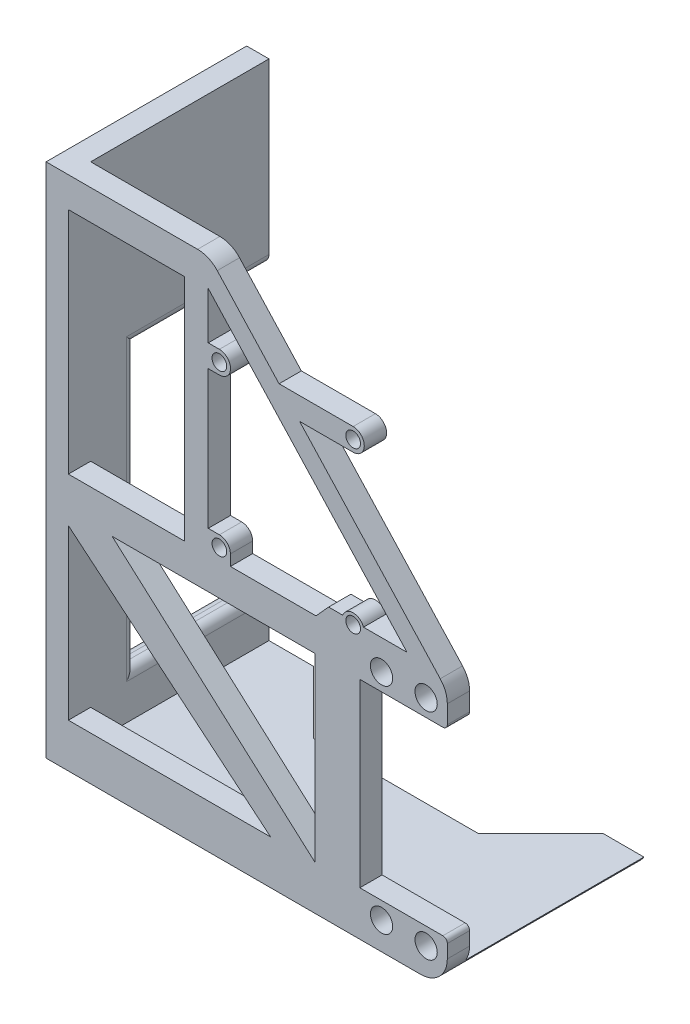
from build123d import *

# Parameters (mm, degrees)
SKETCH_2_R          = 2.5
SKETCH_2_R_2        = 1.65
EXTRUDE_1_DEPTH     = 5
SKETCH_3_W          = 5
SKETCH_3_H          = 7.033503338
EXTRUDE_2_DEPTH     = 40
CUT_EXTRUDE_1_REACH = 7
SKETCH_6_W          = 30
SKETCH_6_H          = 63
CUT_EXTRUDE_2_DEPTH = 10
FILLET_1_R          = 6
FILLET_2_R          = 2
FILLET_3_R          = 1


with BuildPart() as part:
    # 草图2 → 凸台-拉伸1 (new body)
    with BuildSketch(Plane.XY):
        with BuildLine():
            Line((90, -2.836370327), (90, -0.033503338))
            Line((90, -0.033503338), (90, 7.163629673))
            Line((90, 7.163629673), (70.37335416, 7.163629673))
            Line((70.37335416, 7.163629673), (70.37335416, 47.663629673))
            Line((70.37335416, 47.663629673), (90, 47.663629673))
            Line((90, 47.663629673), (90, 55.071074042))
            Line((90, 55.071074042), (56.86982625, 91.020052584))
            Line((56.86982625, 91.020052584), (68.87304018, 91.020052584))
            ThreePointArc((68.87304018, 91.020052584), (71.37304018, 93.520052584), (68.87304018, 96.020052584))
            Line((68.87304018, 96.020052584), (52.261882562, 96.020052584))
            Line((52.261882562, 96.020052584), (36.613354259, 113))
            Line((36.613354259, 113), (0, 113))
            Line((0, 113), (0, 0))
            Line((0, 0), (0, -2.836370327))
            Line((0, -2.836370327), (90, -2.836370327))
        make_face()
        Polygon((5, 7.033503338), (5, 44.840982038), (50.37304018, 7.033503338), (10, 7.033503338), align=None, mode=Mode.SUBTRACT)
        Polygon((60.37304018, 7.033503338), (14.814475837, 47.663629673), (60.37304018, 47.663629673), align=None, mode=Mode.SUBTRACT)
        with Locations((75.24372976, 3.308629673)):
            Circle(SKETCH_2_R, mode=Mode.SUBTRACT)
        with Locations((85.24372976, 3.308629673)):
            Circle(SKETCH_2_R, mode=Mode.SUBTRACT)
        with Locations((75.24372976, 51.518629673)):
            Circle(SKETCH_2_R, mode=Mode.SUBTRACT)
        with Locations((85.24372976, 51.518629673)):
            Circle(SKETCH_2_R, mode=Mode.SUBTRACT)
        Polygon((5, 106.225949783), (31, 106.225949783), (31, 54.840982038), (11.37304018, 54.840982038), (6.37304018, 54.840982038), (5, 54.840982038), (5, 91.020052584), (5, 96.020052584), align=None, mode=Mode.SUBTRACT)
        with Locations((38.87304018, 57.520052584)):
            Circle(SKETCH_2_R_2, mode=Mode.SUBTRACT)
        with Locations((38.87304018, 93.520052584)):
            Circle(SKETCH_2_R_2, mode=Mode.SUBTRACT)
        with BuildLine():
            Line((36.37304018, 106.587975229), (80.964081518, 58.203007486))
            Line((80.964081518, 58.203007486), (71.196585176, 58.203007486))
            ThreePointArc((71.196585176, 58.203007486), (68.87304018, 59.834918346), (66.549495185, 58.203007486))
            Line((66.549495185, 58.203007486), (63.373040182, 58.203007486))
            Line((63.373040182, 58.203007486), (60.53695685, 55.071074042))
            Line((60.53695685, 55.071074042), (41.37304018, 55.071074042))
            Line((41.37304018, 55.071074042), (41.342732423, 55.071074042))
            Line((41.342732423, 55.071074042), (41.342732423, 57.520052584))
            ThreePointArc((41.342732423, 57.520052584), (40.619376312, 59.266388716), (38.87304018, 59.989744826))
            Line((38.87304018, 59.989744826), (36.37304018, 59.989744826))
            Line((36.37304018, 59.989744826), (36.37304018, 91.020052584))
            Line((36.37304018, 91.020052584), (38.87304018, 91.020052584))
            ThreePointArc((38.87304018, 91.020052584), (41.37304018, 93.520052584), (38.87304018, 96.020052584))
            Line((38.87304018, 96.020052584), (36.37304018, 96.020052584))
            Line((36.37304018, 96.020052584), (36.37304018, 106.587975229))
        make_face(mode=Mode.SUBTRACT)
        with BuildLine():
            ThreePointArc((67.371017344, 58.203007486), (68.87304018, 59.170052584), (70.375063017, 58.203007486))
            ThreePointArc((70.375063017, 58.203007486), (70.485621602, 57.869453729), (70.52304018, 57.520052584))
            ThreePointArc((70.52304018, 57.520052584), (68.523639036, 55.907471163), (67.371017344, 58.203007486))
        make_face(mode=Mode.SUBTRACT)
        with Locations((68.87304018, 93.520052584)):
            Circle(SKETCH_2_R_2, mode=Mode.SUBTRACT)
    extrude(amount=EXTRUDE_1_DEPTH)

    # 草图3 → 凸台-拉伸2 (add)
    with BuildSketch(Plane(origin=(0, 0, 0), x_dir=(-1, 0, 0), z_dir=(0, 0, -1))):
        Polygon((0, -2.836370327), (0, 0), (-5, 0), (-90, 0), (-90, -2.836370327), align=None)
        with Locations((-2.5, 3.516751669)):
            Rectangle(SKETCH_3_W, SKETCH_3_H)
        Polygon((-5, 7.033503338), (0, 7.033503338), (0, 113), (-5, 113), (-5, 106.225949783), (-5, 54.840982038), (-5, 44.840982038), align=None)
    extrude(amount=EXTRUDE_2_DEPTH)

    # 草图6 → 切除-拉伸1 (cut, up to next)
    with BuildSketch(Plane(origin=(5, 0, 0), x_dir=(0, 0, -1), z_dir=(1, 0, 0)), mode=Mode.PRIVATE) as cut_extrude_1_sk1:
        with Locations((25, 41.5)):
            Rectangle(SKETCH_6_W, SKETCH_6_H)
    cut_extrude_1_tool1 = extrude(cut_extrude_1_sk1.sketch, amount=-CUT_EXTRUDE_1_REACH, mode=Mode.PRIVATE) & part.part
    add(cut_extrude_1_tool1.solids().sort_by_distance((5, 41.5, -25))[0], mode=Mode.SUBTRACT)

    # 草图7 → 切除-拉伸2 (cut)
    with BuildSketch(Plane(origin=(0, 0, 0), x_dir=(1, 0, 0), z_dir=(0, 1, 0))):
        Polygon((80, 40), (66, 26), (29, 26), (15, 40), align=None)
    extrude(amount=-CUT_EXTRUDE_2_DEPTH, mode=Mode.SUBTRACT)

    # 圆角1
    fillet_1_edges = [part.edges().sort_by_distance(p)[0] for p in [
        (90, -2.836370327, -17.5),
        (90, 55.071074042, 2.5),
        (36.613354259, 113, 2.5),
    ]]
    fillet(fillet_1_edges, radius=FILLET_1_R)

    # 圆角2
    fillet_2_edges = [part.edges().sort_by_distance(p)[0] for p in [
        (0, 73, -25),
        (0, 10, -25),
        (0, 41.5, -10),
        (5, 73, -25),
        (5, 41.5, -10),
        (5, 10, -25),
    ]]
    fillet(fillet_2_edges, radius=FILLET_2_R)

    # 圆角3
    fillet_3_edges = [part.edges().sort_by_distance(p)[0] for p in [
        (90, 47.663629673, 2.5),
        (90, 7.163629673, 2.5),
    ]]
    fillet(fillet_3_edges, radius=FILLET_3_R)


solid = part.part
